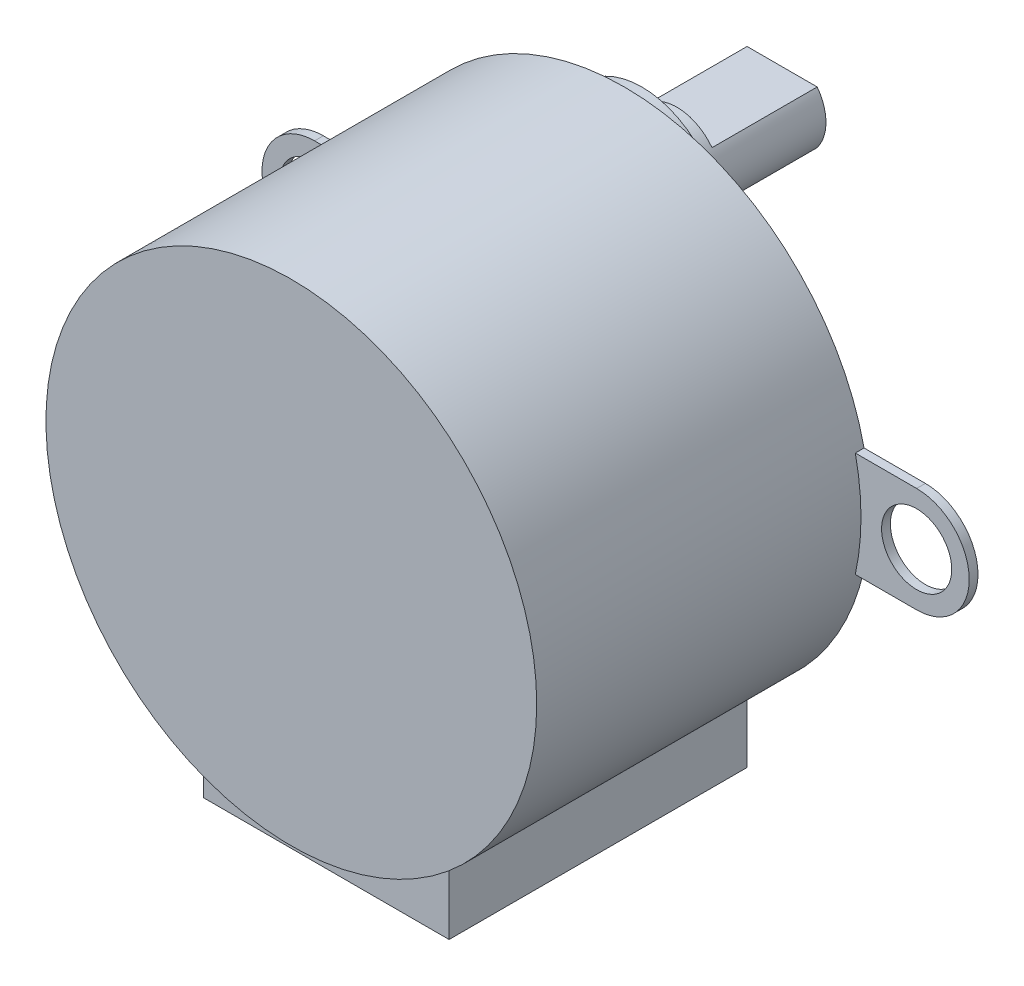
from build123d import *
from build123d.topology import SkipClean

# Parameters (mm, degrees)
SKETCH1_R           = 14
BOSS_EXTRUDE1_DEPTH = 19
SKETCH2_R           = 2
BOSS_EXTRUDE2_DEPTH = 0.5
SKETCH3_R           = 4.5
BOSS_EXTRUDE3_DEPTH = 1
SKETCH4_R           = 2.5
BOSS_EXTRUDE4_DEPTH = 2
BOSS_EXTRUDE5_DEPTH = 6
SKETCH6_W           = 14
SKETCH6_H           = 4
BOSS_EXTRUDE6_DEPTH = 17


with BuildPart() as part:
    # Sketch1 → Boss-Extrude1 (new body)
    with BuildSketch(Plane.XY):
        Circle(SKETCH1_R)
    extrude(amount=BOSS_EXTRUDE1_DEPTH)

    # Sketch2 → Boss-Extrude2 (add)
    # profile 1 of 2: a face of its own
    with BuildSketch(Plane(origin=(0, 0, 0), x_dir=(-1, 0, 0), z_dir=(0, 0, -1))):
        with BuildLine():
            Line((17.174794331, 3), (13.674794331, 3))
            ThreePointArc((13.674794331, 3), (14, 0), (13.674794331, -3))
            Line((13.674794331, -3), (17.174794331, -3))
            ThreePointArc((17.174794331, -3), (20.174794331, 0), (17.174794331, 3))
        make_face()
        with Locations((17.174794331, 0)):
            Circle(SKETCH2_R, mode=Mode.SUBTRACT)
    # profile 2 of 2: a face of its own
    with BuildSketch(Plane(origin=(0, 0, 0), x_dir=(-1, 0, 0), z_dir=(0, 0, -1))):
        with BuildLine():
            Line((-17.174794331, -3), (-13.674794331, -3))
            ThreePointArc((-13.674794331, -3), (-14, 0), (-13.674794331, 3))
            Line((-13.674794331, 3), (-17.174794331, 3))
            ThreePointArc((-17.174794331, 3), (-20.174794331, 0), (-17.174794331, -3))
        make_face()
        with Locations(Location((-17.174794331, 0, 0), (0, 0, 180))):
            Circle(SKETCH2_R, mode=Mode.SUBTRACT)
    extrude(amount=-BOSS_EXTRUDE2_DEPTH)

    # Sketch3 → Boss-Extrude3 (add)
    with BuildSketch(Plane(origin=(0, 0, 0), x_dir=(-1, 0, 0), z_dir=(0, 0, -1))):
        with Locations(Location((0, 9, 0), (0, 0, 180))):
            Circle(SKETCH3_R)
    extrude(amount=BOSS_EXTRUDE3_DEPTH)

    # Sketch4 → Boss-Extrude4 (add)
    with BuildSketch(Plane(origin=(0, 0, -1), x_dir=(-1, 0, 0), z_dir=(0, 0, -1))):
        with Locations((0, 9)):
            Circle(SKETCH4_R)
    extrude(amount=BOSS_EXTRUDE4_DEPTH)

    # Sketch5 → Boss-Extrude5 (add)
    with SkipClean():  # the faces are left unmerged after this step: merging them gives an invalid solid
        with BuildSketch(Plane(origin=(0, 0, -3), x_dir=(-1, 0, 0), z_dir=(0, 0, -1))):
            with BuildLine():
                Line((-2, 10.5), (2, 10.5))
                ThreePointArc((2, 10.5), (2.5, 9), (2, 7.5))
                Line((2, 7.5), (-2, 7.5))
                ThreePointArc((-2, 7.5), (-2.5, 9), (-2, 10.5))
            make_face()
        extrude(amount=BOSS_EXTRUDE5_DEPTH)

    # Sketch6 → Boss-Extrude6 (add)
    with SkipClean():  # the faces are left unmerged after this step: merging them gives an invalid solid
        with BuildSketch(Plane(origin=(0, 0, 0), x_dir=(-1, 0, 0), z_dir=(0, 0, -1))):
            with Locations((0, -14.124355653)):
                Rectangle(SKETCH6_W, SKETCH6_H)
        extrude(amount=-BOSS_EXTRUDE6_DEPTH)


solid = part.part
